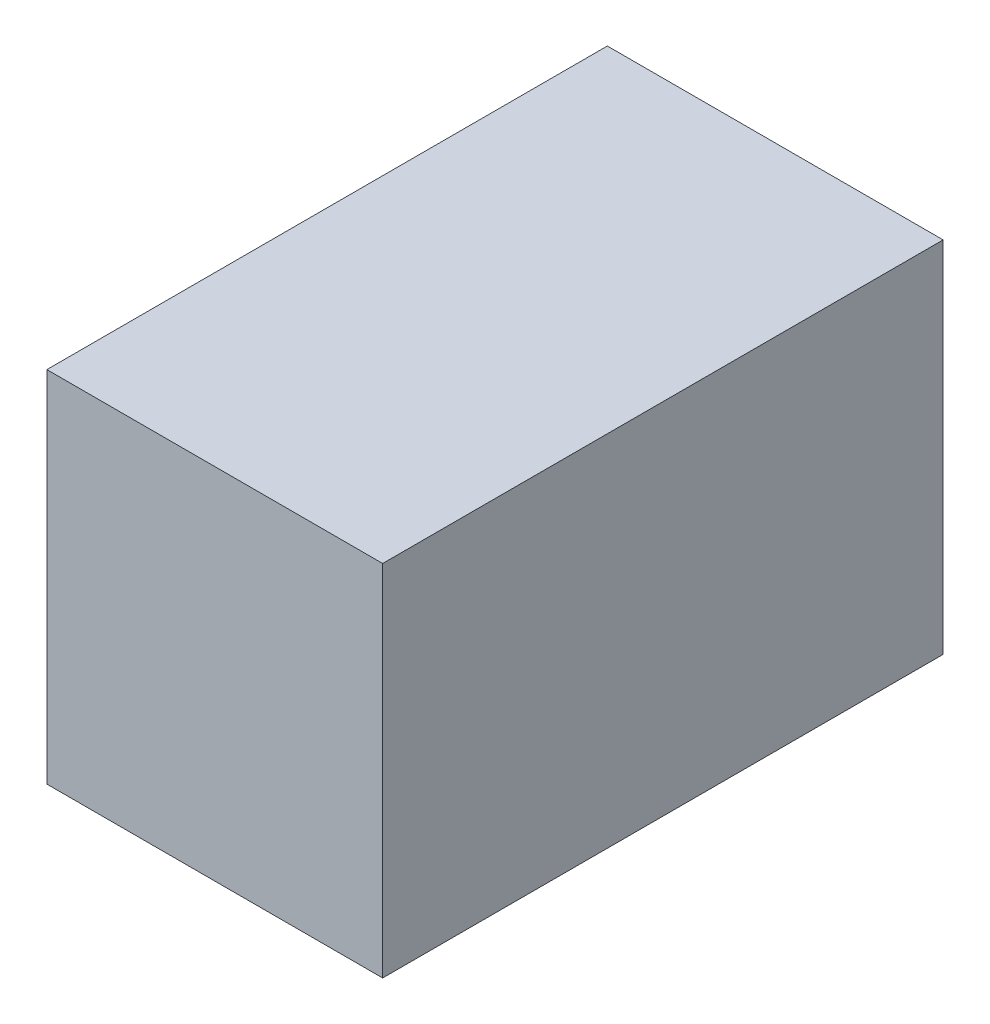
from build123d import *

# Parameters (mm, degrees)
SKETCH4_W           = 31.05
SKETCH4_H           = 18.45
BOSS_EXTRUDE1_DEPTH = 19
SHELL1_T            = 2
SKETCH5_W           = 12
SKETCH5_H           = 18.45
CUT_EXTRUDE1_DEPTH  = 2


with BuildPart() as part:
    # Sketch4 → Boss-Extrude1 (new body)
    with BuildSketch(Plane(origin=(0, 0, 0), x_dir=(0, 0, -1), z_dir=(1, 0, 0))):
        Rectangle(SKETCH4_W, SKETCH4_H)
    extrude(amount=BOSS_EXTRUDE1_DEPTH)

    # Shell1
    shell1_openings = [part.faces().sort_by_distance(p)[0] for p in [
        (0, 0, 0),
    ]]
    offset(amount=SHELL1_T, openings=shell1_openings, kind=Kind.INTERSECTION)

    # Sketch5 → Cut-Extrude1 (cut)
    with BuildSketch(Plane(origin=(0, 0, -17.525), x_dir=(-1, 0, 0), z_dir=(0, 0, -1))):
        with Locations((-6, 0)):
            Rectangle(SKETCH5_W, SKETCH5_H)
    extrude(amount=-CUT_EXTRUDE1_DEPTH, mode=Mode.SUBTRACT)


solid = part.part
